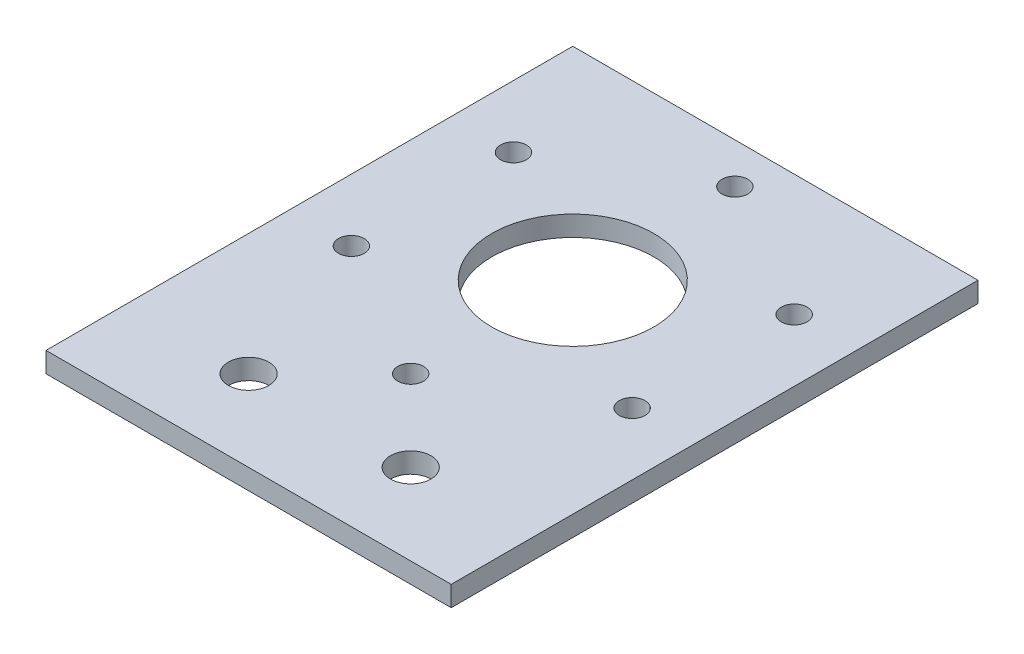
from build123d import *

# Parameters (mm, degrees)
SKETCH1_W           = 63.5
SKETCH1_H           = 82.55
SKETCH1_R           = 12.7
SKETCH1_R_2         = 2.0193
BOSS_EXTRUDE1_DEPTH = 3.175
SKETCH2_R           = 3.175
CUT_EXTRUDE1_DEPTH  = 4.175


with BuildPart() as part:
    # Sketch1 → Boss-Extrude1 (new body)
    with BuildSketch(Plane(origin=(0, 0, 0), x_dir=(1, 0, 0), z_dir=(0, 1, 0))):
        with Locations((31.75, 41.275)):
            Rectangle(SKETCH1_W, SKETCH1_H)
        with Locations((31.75, 50.8)):
            Circle(SKETCH1_R, mode=Mode.SUBTRACT)
        with Locations((9.752954744, 63.5)):
            Circle(SKETCH1_R_2, mode=Mode.SUBTRACT)
        with Locations((31.75, 76.2)):
            Circle(SKETCH1_R_2, mode=Mode.SUBTRACT)
        with Locations((53.747045256, 63.5)):
            Circle(SKETCH1_R_2, mode=Mode.SUBTRACT)
        with Locations((53.747045256, 38.1)):
            Circle(SKETCH1_R_2, mode=Mode.SUBTRACT)
        with Locations((31.75, 25.4)):
            Circle(SKETCH1_R_2, mode=Mode.SUBTRACT)
        with Locations((9.752954744, 38.1)):
            Circle(SKETCH1_R_2, mode=Mode.SUBTRACT)
    extrude(amount=BOSS_EXTRUDE1_DEPTH)

    # Sketch2 → Cut-Extrude1 (cut, through all)
    with BuildSketch(Plane(origin=(0, 3.175, 0), x_dir=(1, 0, 0), z_dir=(0, 1, 0))):
        with Locations((19.05, 12.7)):
            Circle(SKETCH2_R)
        with Locations((44.45, 12.7)):
            Circle(SKETCH2_R)
    extrude(amount=-CUT_EXTRUDE1_DEPTH, mode=Mode.SUBTRACT)


solid = part.part
